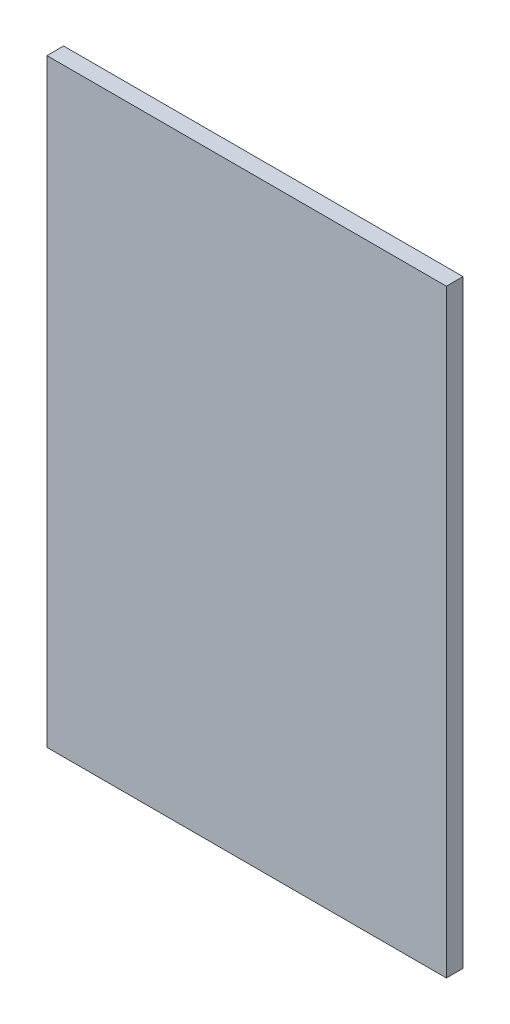
from build123d import *

# Parameters (mm, degrees)
SKETCH1_W           = 120
SKETCH1_H           = 180
BOSS_EXTRUDE1_DEPTH = 5
SKETCH2_W           = 8
SKETCH2_H           = 140
BOSS_EXTRUDE2_DEPTH = 14


with BuildPart() as part:
    # Sketch1 → Boss-Extrude1 (new body)
    with BuildSketch(Plane.XY):
        Rectangle(SKETCH1_W, SKETCH1_H)
    extrude(amount=BOSS_EXTRUDE1_DEPTH)

    # Sketch2 → Boss-Extrude2 (add)
    with BuildSketch(Plane(origin=(0, 0, 0), x_dir=(-1, 0, 0), z_dir=(0, 0, -1))):
        Rectangle(SKETCH2_W, SKETCH2_H)
    extrude(amount=BOSS_EXTRUDE2_DEPTH)


solid = part.part
